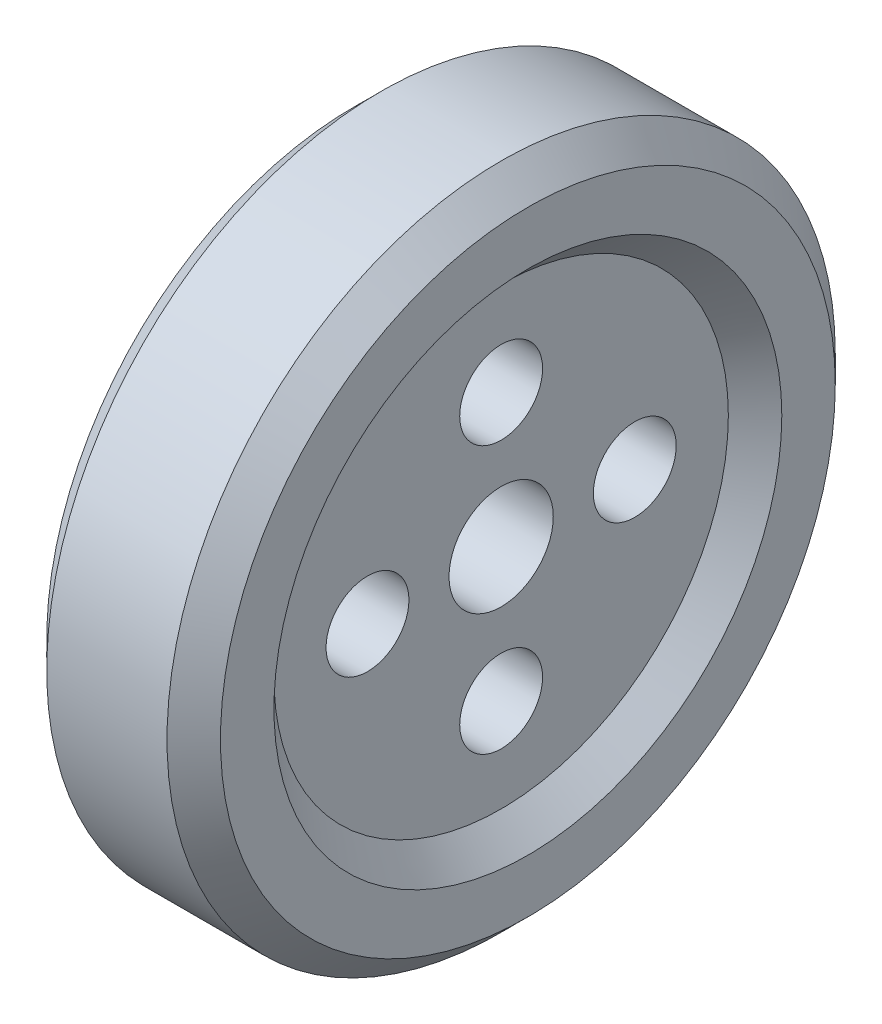
from build123d import *

# Parameters (mm, degrees)
IZIM3_R               = 39
IZIM3_R_2             = 31
KES_EKSTR_ZYON1_DEPTH = 111


with BuildPart() as part:
    # Çizim2 → Döndür1 (revolve)
    with BuildSketch(Plane.XY):
        Polygon((-818.470993896, 390.989010989), (-798.470993896, 370.989010989), (-798.470993896, 330.989010989), (-818.470993896, 310.989010989), (-818.470993896, 140.989010989), (-908.470993896, 140.989010989), (-908.470993896, 310.989010989), (-928.470993896, 330.989010989), (-928.470993896, 370.989010989), (-908.470993896, 390.989010989), align=None)
    revolve(axis=Axis((-690.973356144, 140.989010989, 0), (-1, 0, 0)))

    # Çizim3 → Kes-Ekstrüzyon1 (cut, through all)
    with BuildSketch(Plane.ZY.offset(908.470993896)):
        with Locations((0, 140.989010989)):
            Circle(IZIM3_R)
        with Locations((-100, 140.989010989)):
            Circle(IZIM3_R_2)
        with Locations((0, 240.989010989)):
            Circle(IZIM3_R_2)
        with Locations((100, 140.989010989)):
            Circle(IZIM3_R_2)
        with Locations((0, 40.989010989)):
            Circle(IZIM3_R_2)
    extrude(amount=-KES_EKSTR_ZYON1_DEPTH, mode=Mode.SUBTRACT)


solid = part.part
